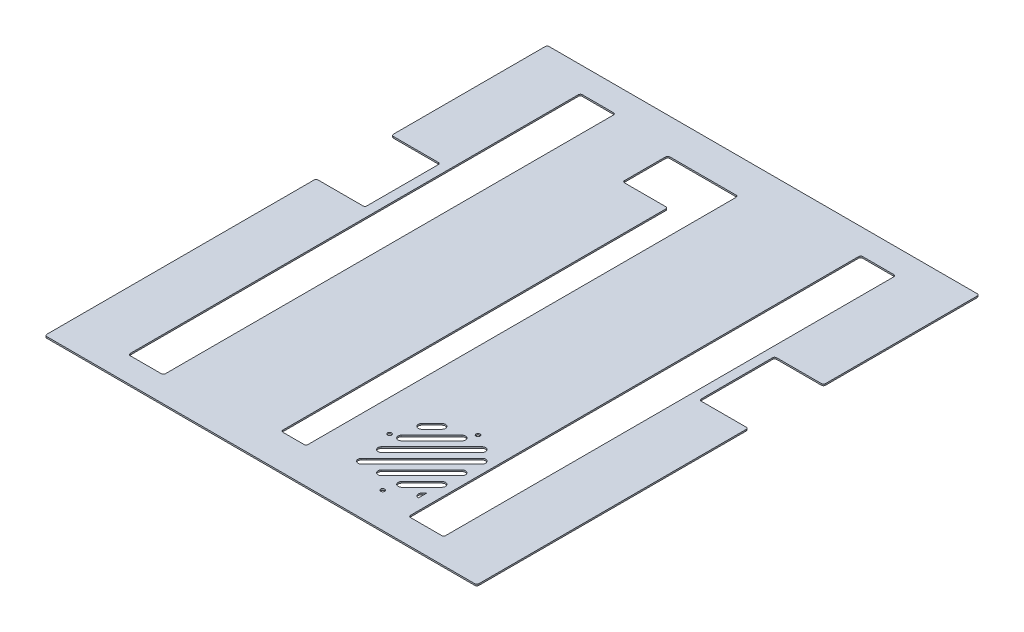
from build123d import *

# Parameters (mm, degrees)
SKETCH1_W           = 430
SKETCH1_H           = 500
BOSS_EXTRUDE1_DEPTH = 1.5
SKETCH2_W           = 48.6
SKETCH2_H           = 75
CUT_EXTRUDE1_DEPTH  = 10
SKETCH3_W           = 35
SKETCH3_H           = 450
CUT_EXTRUDE2_DEPTH  = 10
CUT_EXTRUDE3_DEPTH  = 10
FILLET2_R           = 2
FILLET3_R           = 2
SKETCH6_R           = 2
CUT_EXTRUDE4_DEPTH  = 10


with BuildPart() as part:
    # Sketch1 → Boss-Extrude1 (new body)
    with BuildSketch(Plane(origin=(0, 0, 0), x_dir=(1, 0, 0), z_dir=(0, 1, 0))):
        with Locations((6126.084066999, -8702.312377786)):
            Rectangle(SKETCH1_W, SKETCH1_H)
    extrude(amount=BOSS_EXTRUDE1_DEPTH)

    # Sketch2 → Cut-Extrude1 (cut)
    with BuildSketch(Plane(origin=(0, 1.5, 0), x_dir=(1, 0, 0), z_dir=(0, 1, 0))):
        with Locations((5935.384066999, -8644.812377786)):
            Rectangle(SKETCH2_W, SKETCH2_H)
        with Locations((6316.784066999, -8644.812377786)):
            Rectangle(SKETCH2_W, SKETCH2_H)
    extrude(amount=-CUT_EXTRUDE1_DEPTH, mode=Mode.SUBTRACT)

    # Sketch3 → Cut-Extrude2 (cut)
    with BuildSketch(Plane(origin=(0, 1.5, 0), x_dir=(1, 0, 0), z_dir=(0, 1, 0))):
        Polygon((5969.084066999, -8541.651929061), (5969.084066999, -8927.312377786), (6004.084066999, -8927.312377786), (6004.084066999, -8477.312377786), (5969.084066999, -8477.312377786), align=None)
        with Locations((6265.584066999, -8702.312377786)):
            Rectangle(SKETCH3_W, SKETCH3_H)
        Polygon((6102.084066999, -8487.312377786), (6136.084066999, -8487.312377786), (6136.084066999, -8917.312377786), (6111.084066999, -8917.312377786), (6111.084066999, -8532.312377786), (6066.084066999, -8532.312377786), (6066.084066999, -8487.312377786), align=None)
    extrude(amount=-CUT_EXTRUDE2_DEPTH, mode=Mode.SUBTRACT)

    # Sketch4 → Cut-Extrude3 (cut)
    with BuildSketch(Plane(origin=(0, 1.5, 0), x_dir=(1, 0, 0), z_dir=(0, 1, 0))):
        with BuildLine():
            Line((6234.584067167, -8840.596520357), (6177.084066999, -8898.096518708))
            Line((6177.084066999, -8898.096518708), (6174.584066999, -8900.596520951))
            ThreePointArc((6174.584066999, -8900.596520951), (6174.584069168, -8905.596518633), (6179.584066849, -8905.596518637))
            Line((6179.584066849, -8905.596518637), (6237.084067092, -8848.09652021))
            Line((6237.084067092, -8848.09652021), (6239.584067017, -8845.596520364))
            ThreePointArc((6239.584067017, -8845.596520364), (6239.584067096, -8840.596520436), (6234.584067167, -8840.596520357))
        make_face()
        with BuildLine():
            ThreePointArc((6174.584067387, -8880.596519018), (6174.584067598, -8885.596518612), (6179.584067193, -8885.596518982))
            Line((6179.584067193, -8885.596518982), (6229.584067988, -8835.596519766))
            ThreePointArc((6229.584067988, -8835.596519766), (6229.584069287, -8830.596518949), (6224.584068469, -8830.596519802))
            Line((6224.584068469, -8830.596519802), (6222.084069197, -8833.096518708))
            Line((6222.084069197, -8833.096518708), (6174.584067387, -8880.596519018))
        make_face()
        with BuildLine():
            ThreePointArc((6174.584067774, -8860.596519406), (6174.584068372, -8865.596518614), (6179.58406758, -8865.59651937))
            Line((6179.58406758, -8865.59651937), (6209.58406806, -8835.596519838))
            ThreePointArc((6209.58406806, -8835.596519838), (6209.584069287, -8830.596518805), (6204.584068253, -8830.596519874))
            Line((6204.584068253, -8830.596519874), (6174.584067774, -8860.596519406))
        make_face()
        with BuildLine():
            Line((6219.584066911, -8905.596518637), (6239.584067017, -8885.596519163))
            ThreePointArc((6239.584067017, -8885.596519163), (6239.584067096, -8880.596519234), (6234.584067167, -8880.596519155))
            Line((6234.584067167, -8880.596519155), (6214.584067061, -8900.596518629))
            ThreePointArc((6214.584067061, -8900.596518629), (6214.584066907, -8905.596518633), (6219.584066911, -8905.596518637))
        make_face()
        with BuildLine():
            ThreePointArc((6174.584068161, -8840.596519795), (6174.584069146, -8845.596518616), (6179.584067967, -8845.596519759))
            Line((6179.584067967, -8845.596519759), (6189.584068132, -8835.59651991))
            ThreePointArc((6189.584068132, -8835.59651991), (6189.584069431, -8830.596518805), (6184.584068325, -8830.596519946))
            Line((6184.584068325, -8830.596519946), (6174.584068161, -8840.596519795))
        make_face()
        with BuildLine():
            Line((6234.584067693, -8860.59651923), (6194.58406703, -8900.596518629))
            ThreePointArc((6194.58406703, -8900.596518629), (6194.584066876, -8905.596518633), (6199.58406688, -8905.596518637))
            Line((6199.58406688, -8905.596518637), (6237.084067092, -8868.096519609))
            Line((6237.084067092, -8868.096519609), (6239.584067543, -8865.596517133))
            ThreePointArc((6239.584067543, -8865.596517133), (6239.584066044, -8860.596518783), (6234.584067693, -8860.59651923))
        make_face()
        with BuildLine():
            Line((6237.084067092, -8898.096518708), (6234.584067092, -8900.596518629))
            ThreePointArc((6234.584067092, -8900.596518629), (6233.817659407, -8904.449508447), (6237.084067092, -8906.632051027))
            Line((6237.084067092, -8906.632051027), (6237.084067092, -8898.096518708))
        make_face()
    extrude(amount=-CUT_EXTRUDE3_DEPTH, mode=Mode.SUBTRACT)

    # Fillet2
    fillet2_edges = [part.edges().sort_by_distance(p)[0] for p in [
        (5959.684066999, 0.75, 8607.312377786),
        (5959.684066999, 0.75, 8682.312377786),
        (5911.084066999, 0.75, 8682.312377786),
        (5911.084066999, 0.75, 8607.312377786),
        (6341.084066999, 0.75, 8607.312377786),
        (6341.084066999, 0.75, 8682.312377786),
        (6292.484066999, 0.75, 8682.312377786),
        (6292.484066999, 0.75, 8607.312377786),
        (5911.084066999, 0.75, 8452.312377786),
        (6341.084066999, 0.75, 8452.312377786),
        (6341.084066999, 0.75, 8952.312377786),
        (5911.084066999, 0.75, 8952.312377786),
    ]]
    fillet(fillet2_edges, radius=FILLET2_R)

    # Fillet3
    fillet3_edges = [part.edges().sort_by_distance(p)[0] for p in [
        (6283.084066999, 0.75, 8477.312377786),
        (6283.084066999, 0.75, 8927.312377786),
        (6248.084066999, 0.75, 8927.312377786),
        (6248.084066999, 0.75, 8477.312377786),
        (5969.084066999, 0.75, 8477.312377786),
        (6004.084066999, 0.75, 8477.312377786),
        (6004.084066999, 0.75, 8927.312377786),
        (5969.084066999, 0.75, 8927.312377786),
        (6066.084066999, 0.75, 8532.312377786),
        (6066.084066999, 0.75, 8487.312377786),
        (6136.084066999, 0.75, 8487.312377786),
        (6136.084066999, 0.75, 8917.312377786),
        (6111.084066999, 0.75, 8917.312377786),
        (6111.084066999, 0.75, 8532.312377786),
    ]]
    fillet(fillet3_edges, radius=FILLET3_R)

    # Sketch6 → Cut-Extrude4 (cut)
    with BuildSketch(Plane(origin=(0, 1.5, 0), x_dir=(1, 0, 0), z_dir=(0, 1, 0))):
        with Locations((6212.584066999, -8822.590833806)):
            Circle(SKETCH6_R)
        with Locations((6212.584066999, -8917.590833806)):
            Circle(SKETCH6_R)
        with Locations((6167.584066999, -8865.596518708)):
            Circle(SKETCH6_R)
    extrude(amount=-CUT_EXTRUDE4_DEPTH, mode=Mode.SUBTRACT)


solid = part.part
